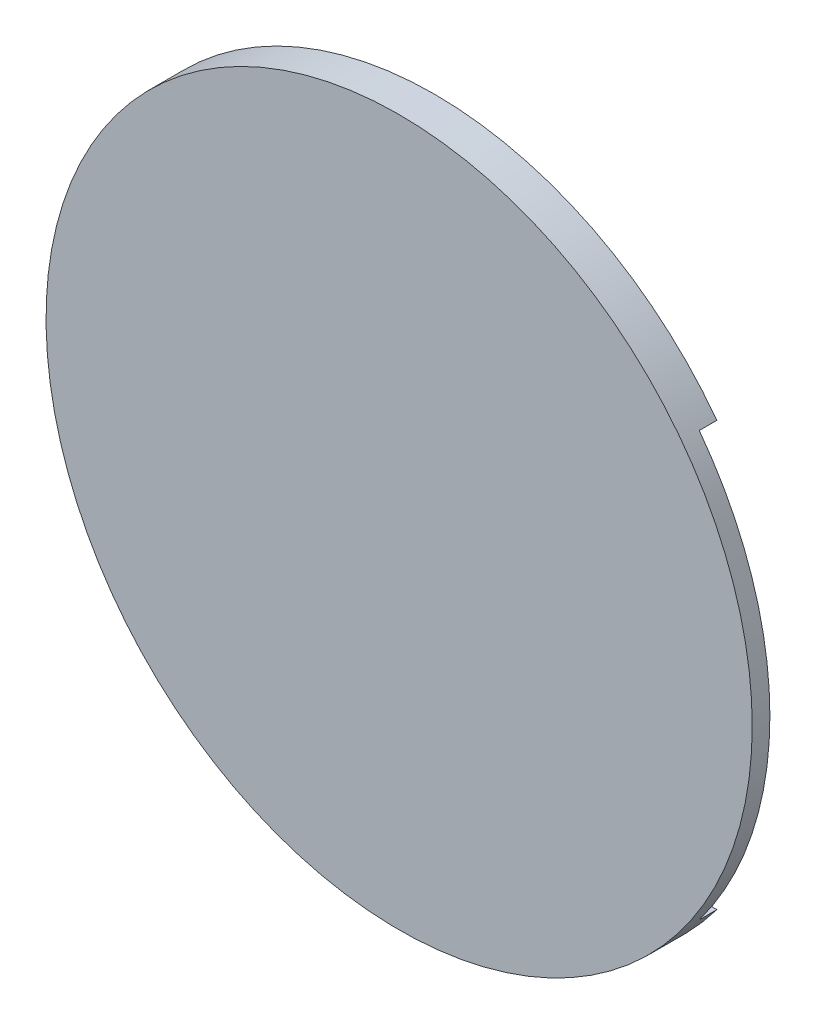
from build123d import *

# Parameters (mm, degrees)
SKETCH1_R    = 31.75
BASE_DEPTH   = 1.5875
TRENCH_DEPTH = 31.75


with BuildPart() as part:
    # Sketch1 → Base (new body, symmetric)
    with BuildSketch(Plane.XY):
        Circle(SKETCH1_R)
    extrude(amount=BASE_DEPTH, both=True)

    # Sketch5 → Trench (cut, symmetric)
    with BuildSketch(Plane(origin=(0, 0, 0), x_dir=(0, 0, -1), z_dir=(1, 0, 0))):
        with BuildLine():
            Line((0, -19.05), (1.5875, -19.05))
            ThreePointArc((1.5875, -19.05), (0.397561674, -9.558016141), (0, -8.92e-07))
            Line((0, -8.92e-07), (0, -19.05))
        make_face()
        with BuildLine():
            ThreePointArc((0, -8.92e-07), (0.3975616, 9.558015252), (1.5875, 19.05))
            Line((1.5875, 19.05), (0, 19.05))
            Line((0, 19.05), (0, -8.92e-07))
        make_face()
        with BuildLine():
            Line((1.5875, 19.05), (1.5875, -19.05))
            ThreePointArc((1.5875, -19.05), (0, 0), (1.5875, 19.05))
        make_face()
    extrude(amount=TRENCH_DEPTH, both=True, mode=Mode.SUBTRACT)


solid = part.part
